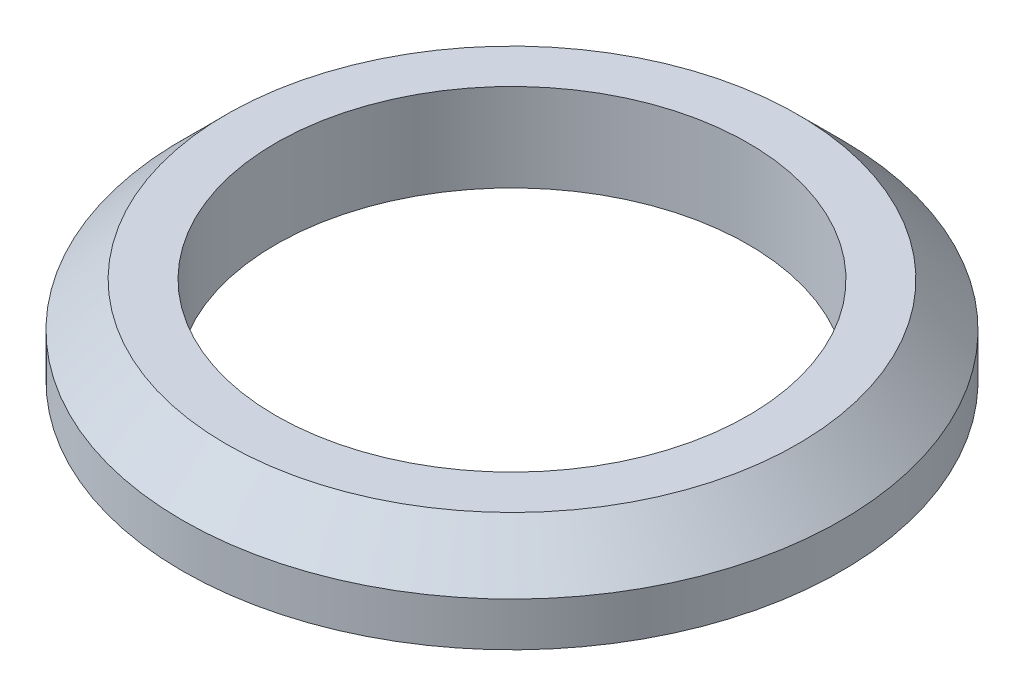
from build123d import *

# Parameters (mm, degrees)
SKETCH1_R           = 3
SKETCH1_R_2         = 2.15
BOSS_EXTRUDE1_DEPTH = 0.8
CHAMFER1_SIZE       = 0.4


with BuildPart() as part:
    # Sketch1 → Boss-Extrude1 (new body)
    with BuildSketch(Plane(origin=(0, 0, 0), x_dir=(1, 0, 0), z_dir=(0, 1, 0))):
        Circle(SKETCH1_R)
        Circle(SKETCH1_R_2, mode=Mode.SUBTRACT)
    extrude(amount=BOSS_EXTRUDE1_DEPTH)

    # Chamfer1
    chamfer1_edges = [part.edges().sort_by_distance(p)[0] for p in [
        (-3, 0.8, 0),
    ]]
    chamfer(chamfer1_edges, length=CHAMFER1_SIZE)


solid = part.part
